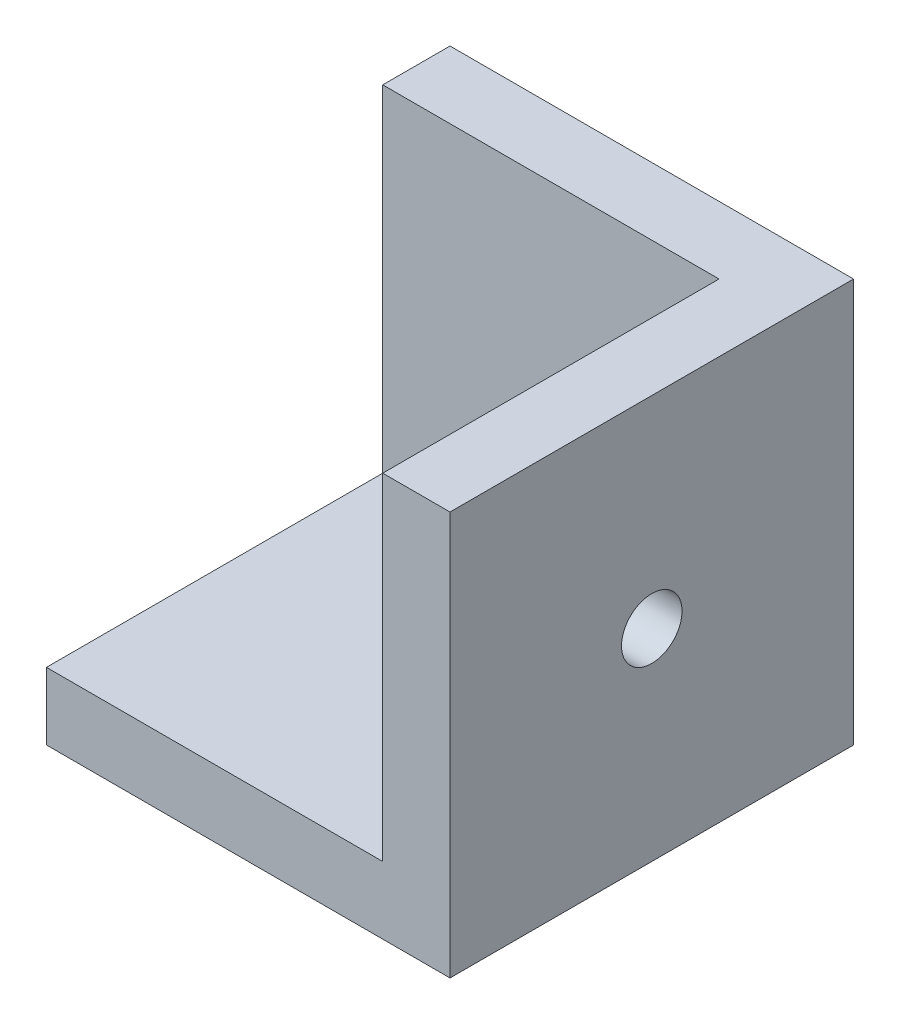
from build123d import *

# Parameters (mm, degrees)
ESBO_O1_W                         = 30
ESBO_O1_H                         = 30
RESSALTO_EXTRUS_O1_DEPTH          = 30
ESBO_O3_W                         = 25
ESBO_O3_H                         = 25
CORTE_EXTRUS_O2_DEPTH             = 25
FURO_COM_FOLGA_DE_M41_D           = 4.5
FURO_COM_FOLGA_DE_M41_ON_FACE_2_D = 4.5
FURO_COM_FOLGA_DE_M41_ON_FACE_3_D = 4.5


with BuildPart() as part:
    # Esboço1 → Ressalto-extrusão1 (new body)
    with BuildSketch(Plane.XY):
        with Locations((-15, 15)):
            Rectangle(ESBO_O1_W, ESBO_O1_H)
    extrude(amount=RESSALTO_EXTRUS_O1_DEPTH)

    # Esboço3 → Corte-extrusão2 (cut)
    with BuildSketch(Plane(origin=(0, 30, 0), x_dir=(1, 0, 0), z_dir=(0, 1, 0))):
        with Locations((-17.5, -17.5)):
            Rectangle(ESBO_O3_W, ESBO_O3_H)
    extrude(amount=-CORTE_EXTRUS_O2_DEPTH, mode=Mode.SUBTRACT)

    # Furo com folga de M41 (through all)
    with Locations(Plane(origin=(-5, 15, 15), x_dir=(0, 0, -1), z_dir=(-1, 0, 0))):
        with Locations((0, 0)):
            Hole(FURO_COM_FOLGA_DE_M41_D / 2)

    # Furo com folga de M41 on face 2 (through all)
    with Locations(Plane(origin=(-15, 15, 5), x_dir=(1, 0, 0), z_dir=(0, 0, 1))):
        with Locations((0, 0)):
            Hole(FURO_COM_FOLGA_DE_M41_ON_FACE_2_D / 2)

    # Furo com folga de M41 on face 3 (through all)
    with Locations(Plane(origin=(-15, 5, 15), x_dir=(0, 0, 1), z_dir=(0, 1, 0))):
        with Locations((0, 0)):
            Hole(FURO_COM_FOLGA_DE_M41_ON_FACE_3_D / 2)


solid = part.part
